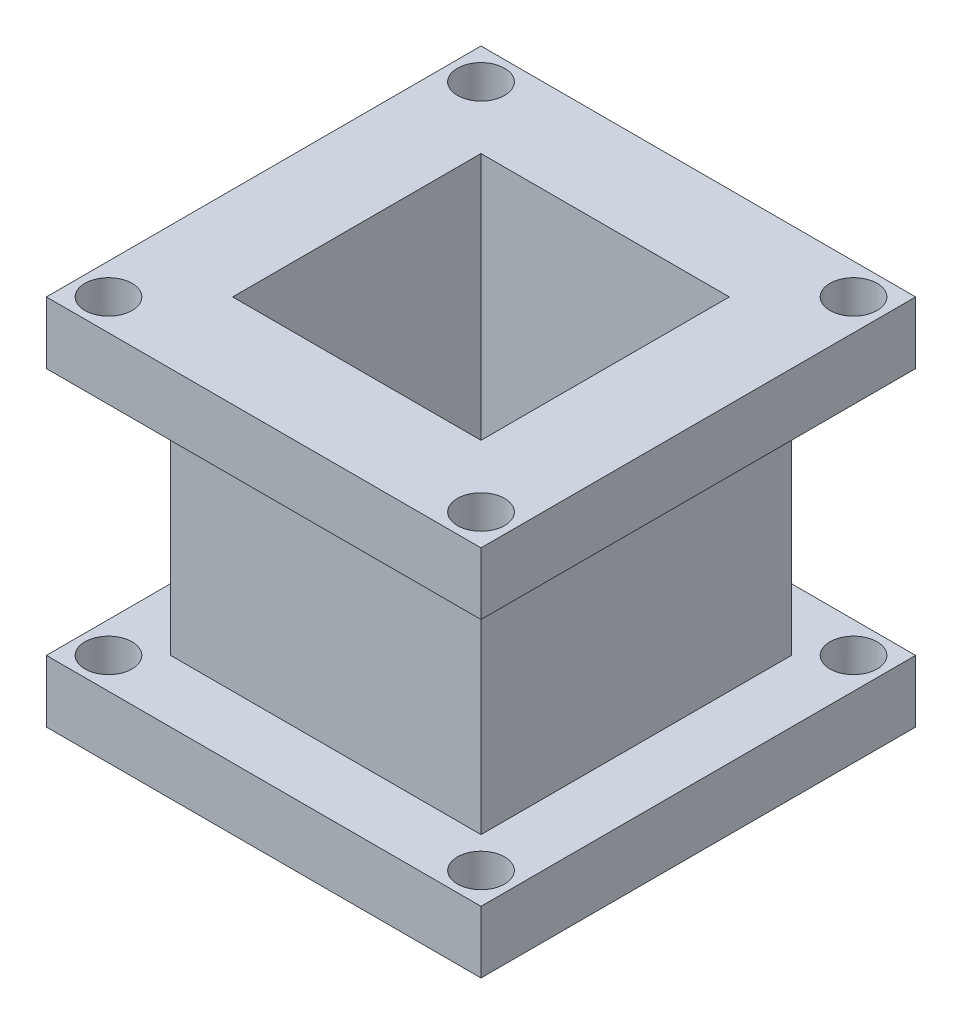
from build123d import *

# Parameters (mm, degrees)
SKETCH1_W           = 44.45
SKETCH1_H           = 44.45
BOSS_EXTRUDE1_DEPTH = 6.35
SKETCH2_W           = 31.75
SKETCH2_H           = 31.75
BOSS_EXTRUDE2_DEPTH = 25.4
SKETCH3_W           = 44.45
SKETCH3_H           = 44.45
BOSS_EXTRUDE3_DEPTH = 6.35
SKETCH4_W           = 25.4
SKETCH4_H           = 25.4
CUT_EXTRUDE1_DEPTH  = 50.391408666
SKETCH6_R           = 2.413
CUT_EXTRUDE3_DEPTH  = 45.676210112
CIRPATTERN1_COUNT   = 4


with BuildPart() as part:
    # Sketch1 → Boss-Extrude1 (new body)
    with BuildSketch(Plane(origin=(0, 0, 0), x_dir=(1, 0, 0), z_dir=(0, 1, 0))):
        Rectangle(SKETCH1_W, SKETCH1_H)
    extrude(amount=BOSS_EXTRUDE1_DEPTH)

    # Sketch2 → Boss-Extrude2 (add)
    with BuildSketch(Plane(origin=(0, 6.35, 0), x_dir=(1, 0, 0), z_dir=(0, 1, 0))):
        Rectangle(SKETCH2_W, SKETCH2_H)
    extrude(amount=BOSS_EXTRUDE2_DEPTH)

    # Sketch3 → Boss-Extrude3 (add)
    with BuildSketch(Plane(origin=(0, 31.75, 0), x_dir=(1, 0, 0), z_dir=(0, 1, 0))):
        Rectangle(SKETCH3_W, SKETCH3_H)
    extrude(amount=BOSS_EXTRUDE3_DEPTH)

    # Sketch4 → Cut-Extrude1 (cut, through all)
    with BuildSketch(Plane(origin=(0, 38.1, 0), x_dir=(1, 0, 0), z_dir=(0, 1, 0))):
        Rectangle(SKETCH4_W, SKETCH4_H)
    extrude(amount=-CUT_EXTRUDE1_DEPTH, mode=Mode.SUBTRACT)

    # Sketch6 → Cut-Extrude3 (cut, symmetric)
    with BuildSketch(Plane.XZ.offset(-31.75)):
        with Locations((19.05, 19.05)):
            Circle(SKETCH6_R)
    cut_extrude3 = extrude(amount=CUT_EXTRUDE3_DEPTH, both=True, mode=Mode.SUBTRACT)

    # CirPattern1: Cut-Extrude3 ×4 about axis
    cirpattern1_axis = Axis((0, -1.905, 0), (0, 1, 0))
    for i in range(1, CIRPATTERN1_COUNT):
        add(cut_extrude3.rotate(cirpattern1_axis, i * 360 / CIRPATTERN1_COUNT), mode=Mode.SUBTRACT)


solid = part.part
